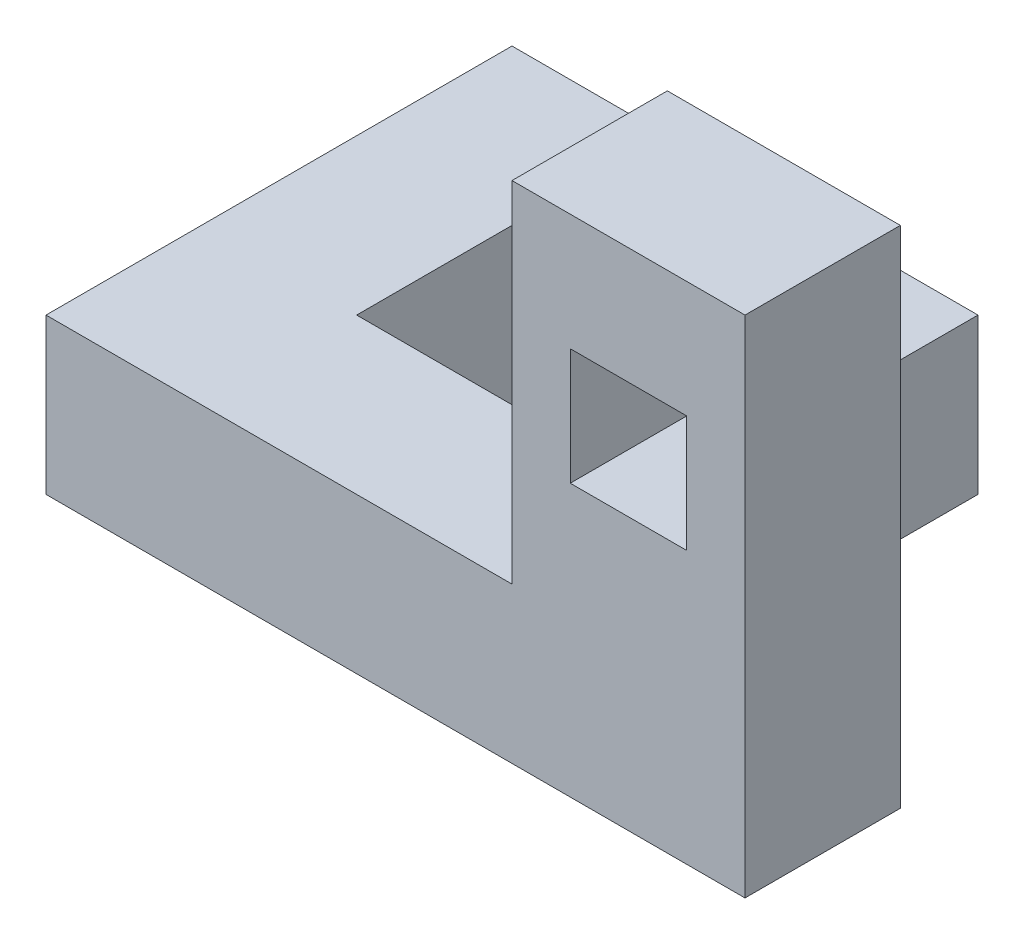
from build123d import *

# Parameters (mm, degrees)
SKETCH1_W           = 60
SKETCH1_H           = 60
SKETCH1_W_2         = 20
SKETCH1_H_2         = 20
BOSS_EXTRUDE1_DEPTH = 20
SKETCH2_W           = 30
SKETCH2_H           = 65
SKETCH2_W_2         = 15
SKETCH2_H_2         = 15
BOSS_EXTRUDE2_DEPTH = 20


with BuildPart() as part:
    # Sketch1 → Boss-Extrude1 (new body)
    with BuildSketch(Plane(origin=(0, 0, 0), x_dir=(1, 0, 0), z_dir=(0, 1, 0))):
        Rectangle(SKETCH1_W, SKETCH1_H)
        Rectangle(SKETCH1_W_2, SKETCH1_H_2, mode=Mode.SUBTRACT)
    extrude(amount=BOSS_EXTRUDE1_DEPTH)

    # Sketch2 → Boss-Extrude2 (add)
    with BuildSketch(Plane.XY.offset(30)):
        with Locations((45, 32.5)):
            Rectangle(SKETCH2_W, SKETCH2_H)
        with Locations((45, 42.5)):
            Rectangle(SKETCH2_W_2, SKETCH2_H_2, mode=Mode.SUBTRACT)
    extrude(amount=-BOSS_EXTRUDE2_DEPTH)


solid = part.part
